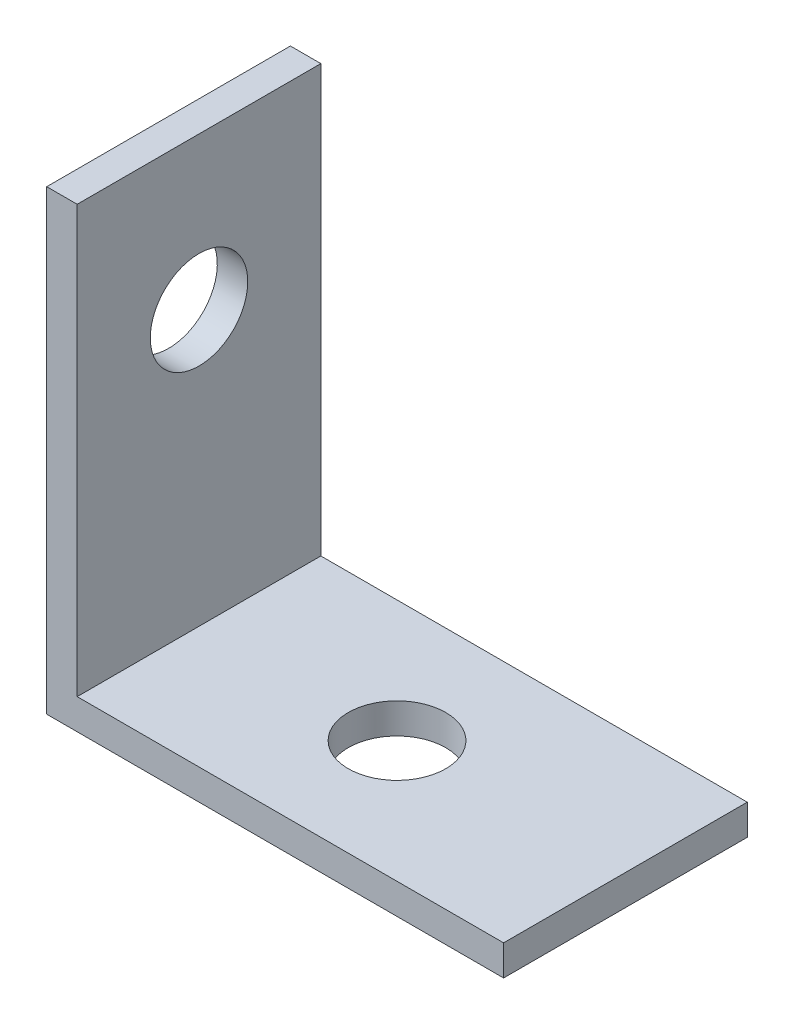
from build123d import *

# Parameters (mm, degrees)
EXTRUDE_1_DEPTH    = 8
SKETCH1_R          = 1.6
CUT_EXTRUDE1_DEPTH = 2
SKETCH_2_R         = 1.6
CUT_EXTRUDE2_DEPTH = 16


with BuildPart() as part:
    # Эскиз1 → Бобышка-Вытянуть1 (new body)
    with BuildSketch(Plane.XY):
        Polygon((0, 0), (15, 0), (15, 1), (1, 1), (1, 15), (0, 15), align=None)
    extrude(amount=EXTRUDE_1_DEPTH)

    # Sketch1 → Cut-Extrude1 (cut, through all)
    with BuildSketch(Plane(origin=(1, 0, 0), x_dir=(0, 0, -1), z_dir=(1, 0, 0))):
        with Locations((-4, 10)):
            Circle(SKETCH1_R)
    extrude(amount=-CUT_EXTRUDE1_DEPTH, mode=Mode.SUBTRACT)

    # Эскиз2 → Cut-Extrude2 (cut, through all)
    with BuildSketch(Plane.XZ):
        with Locations((7.5, 4)):
            Circle(SKETCH_2_R)
    extrude(amount=-CUT_EXTRUDE2_DEPTH, mode=Mode.SUBTRACT)


solid = part.part
